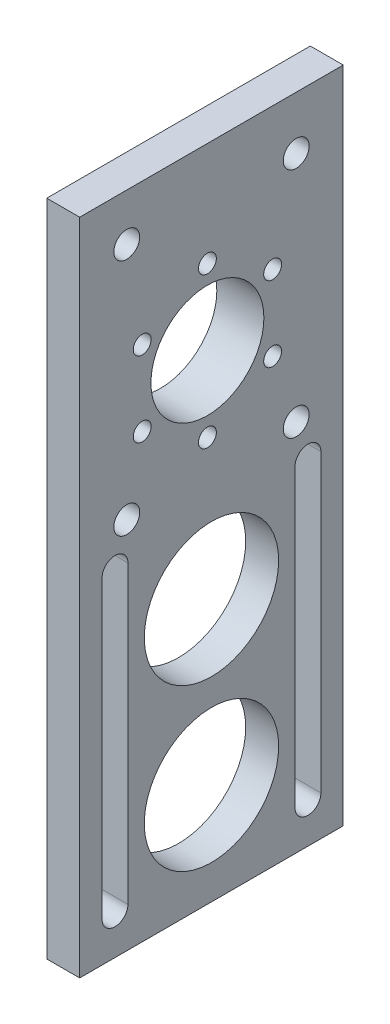
from build123d import *

# Parameters (mm, degrees)
SKETCH1_W           = 56
SKETCH1_H           = 140
BOSS_EXTRUDE1_DEPTH = 7
SKETCH2_R           = 14.275
SKETCH2_R_2         = 12
SKETCH2_R_3         = 1.9
CUT_EXTRUDE1_DEPTH  = 8
CUT_EXTRUDE2_DEPTH  = 8
SKETCH4_R           = 2.75
CUT_EXTRUDE3_DEPTH  = 8
BOSS_EXTRUDE3_DEPTH = 3
SKETCH8_R           = 1.9
SKETCH8_R_2         = 12
CUT_EXTRUDE5_DEPTH  = 4


with BuildPart() as part:
    # Sketch1 → Boss-Extrude1 (new body)
    with BuildSketch(Plane(origin=(0, 0, 0), x_dir=(0, 0, -1), z_dir=(1, 0, 0))):
        with Locations((28, 70)):
            Rectangle(SKETCH1_W, SKETCH1_H)
    extrude(amount=BOSS_EXTRUDE1_DEPTH)

    # Sketch2 → Cut-Extrude1 (cut, through all)
    with BuildSketch(Plane(origin=(7, 0, 0), x_dir=(0, 0, -1), z_dir=(1, 0, 0))):
        with Locations((28, 21.516289278)):
            Circle(SKETCH2_R)
        with Locations((28, 55.727598477)):
            Circle(SKETCH2_R)
        with Locations((27.137621846, 101.914121241)):
            Circle(SKETCH2_R_2)
        with Locations((40.994028307, 109.914121241)):
            Circle(SKETCH2_R_3)
        with Locations((27.137621846, 117.914121241)):
            Circle(SKETCH2_R_3)
        with Locations((13.281215386, 109.914121241)):
            Circle(SKETCH2_R_3)
        with Locations((40.994028307, 93.914121241)):
            Circle(SKETCH2_R_3)
        with Locations((27.137621846, 85.914121241)):
            Circle(SKETCH2_R_3)
        with Locations((13.281215386, 93.914121241)):
            Circle(SKETCH2_R_3)
    extrude(amount=-CUT_EXTRUDE1_DEPTH, mode=Mode.SUBTRACT)

    # Sketch3 → Cut-Extrude2 (cut, through all)
    with BuildSketch(Plane(origin=(7, 0, 0), x_dir=(0, 0, -1), z_dir=(1, 0, 0))):
        with BuildLine():
            Line((10.25, 71.244817418), (10.25, 8.434985259))
            ThreePointArc((10.25, 8.434985259), (7.5, 5.684985259), (4.75, 8.434985259))
            Line((4.75, 8.434985259), (4.75, 71.244817418))
            ThreePointArc((4.75, 71.244817418), (7.5, 73.994817418), (10.25, 71.244817418))
        make_face()
        with BuildLine():
            Line((45.75, 8.434985259), (45.75, 71.244817418))
            ThreePointArc((45.75, 71.244817418), (48.5, 73.994817418), (51.25, 71.244817418))
            Line((51.25, 71.244817418), (51.25, 8.434985259))
            ThreePointArc((51.25, 8.434985259), (48.5, 5.684985259), (45.75, 8.434985259))
        make_face()
    extrude(amount=-CUT_EXTRUDE2_DEPTH, mode=Mode.SUBTRACT)

    # Sketch4 → Cut-Extrude3 (cut, through all)
    with BuildSketch(Plane(origin=(7, 0, 0), x_dir=(0, 0, -1), z_dir=(1, 0, 0))):
        with Locations((10, 130)):
            Circle(SKETCH4_R)
        with Locations((46, 128.741828228)):
            Circle(SKETCH4_R)
        with Locations((46, 79.350819397)):
            Circle(SKETCH4_R)
        with Locations((10, 79.350819397)):
            Circle(SKETCH4_R)
    extrude(amount=-CUT_EXTRUDE3_DEPTH, mode=Mode.SUBTRACT)

    # Sketch7 → Boss-Extrude3 (add)
    with BuildSketch(Plane.ZY):
        Polygon((-10.64359884, 111.154642842), (-26.893136794, 120.818624975), (-43.3871598, 111.578103374), (-43.631644852, 92.673599639), (-27.382106898, 83.009617506), (-10.888083892, 92.250139107), align=None)
    extrude(amount=BOSS_EXTRUDE3_DEPTH)

    # Sketch8 → Cut-Extrude5 (cut, through all)
    with BuildSketch(Plane(origin=(0, 0, 0), x_dir=(0, 0, -1), z_dir=(1, 0, 0))):
        with Locations((13.281215386, 109.914121241)):
            Circle(SKETCH8_R)
        with Locations((13.281215386, 93.914121241)):
            Circle(SKETCH8_R)
        with Locations((27.137621846, 85.914121241)):
            Circle(SKETCH8_R)
        with Locations((40.994028307, 93.914121241)):
            Circle(SKETCH8_R)
        with Locations((40.994028307, 109.914121241)):
            Circle(SKETCH8_R)
        with Locations((27.137621846, 117.914121241)):
            Circle(SKETCH8_R)
        with Locations((27.137621846, 101.914121241)):
            Circle(SKETCH8_R_2)
    extrude(amount=-CUT_EXTRUDE5_DEPTH, mode=Mode.SUBTRACT)


solid = part.part
